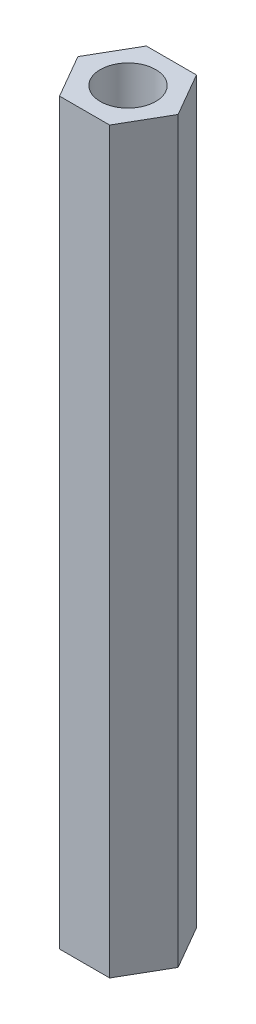
from build123d import *

# Parameters (mm, degrees)
SKETCH_1_R      = 1.5
EXTRUDE_1_DEPTH = 40


with BuildPart() as part:
    # 草图1 → 凸台-拉伸1 (new body)
    with BuildSketch(Plane(origin=(0, 0, 0), x_dir=(1, 0, 0), z_dir=(0, 1, 0))):
        Polygon((-1.356773133, 2.35), (1.356773133, 2.35), (2.713546265, 0), (1.356773133, -2.35), (-1.356773133, -2.35), (-2.713546265, 0), align=None)
        Circle(SKETCH_1_R, mode=Mode.SUBTRACT)
    extrude(amount=EXTRUDE_1_DEPTH)


solid = part.part
